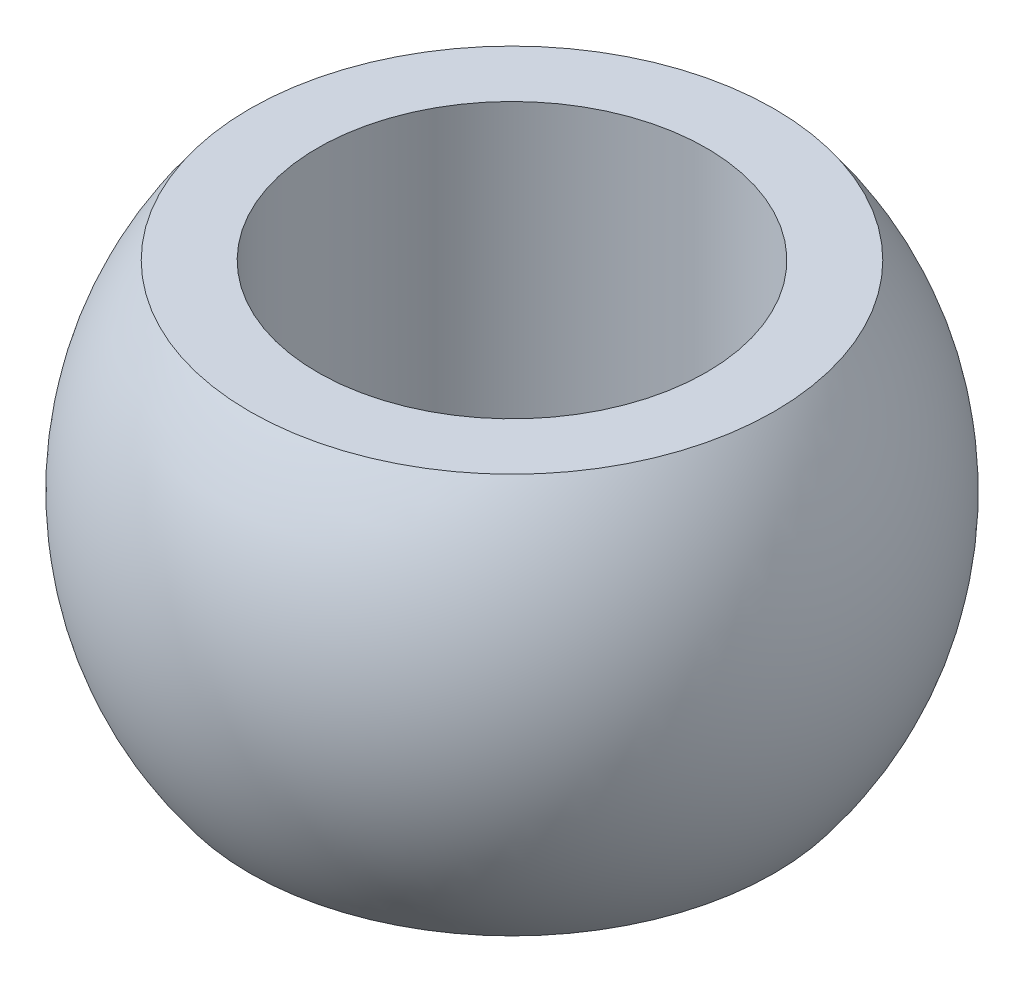
from build123d import *


with BuildPart() as part:
    # Sketch1 → Revolve1 (revolve)
    with BuildSketch(Plane.XY):
        with BuildLine():
            Line((1.88865693, 1.44), (1.4, 1.44))
            Line((1.4, 1.44), (1.4, -1.44))
            Line((1.4, -1.44), (1.88865693, -1.44))
            ThreePointArc((1.88865693, -1.44), (2.375, 0), (1.88865693, 1.44))
        make_face()
    revolve(axis=Axis((0, -449.643937115, 0), (0, 1, 0)))


solid = part.part
